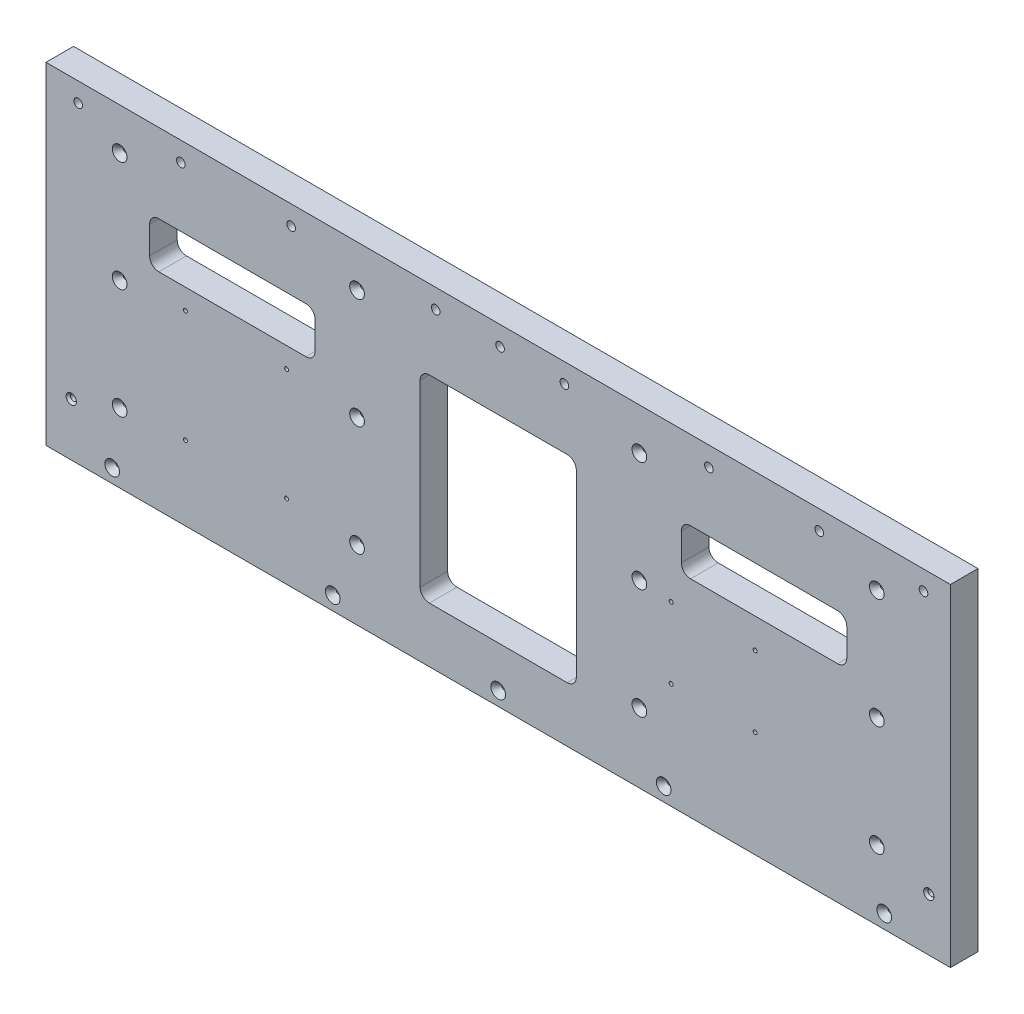
from build123d import *

# Parameters (mm, degrees)
SKETCH1_W                                         = 624.84
SKETCH1_H                                         = 229.235
BOSS_EXTRUDE1_DEPTH                               = 19.05
F_5_64_0_07813_DIAMETER_HOLE1_D                   = 3.175
F_5_64_0_07813_DIAMETER_HOLE1_DEPTH               = 38.1
F_5_64_0_07813_DIAMETER_HOLE1_CSINK_D             = 10.16
F_5_64_0_07813_DIAMETER_HOLE1_CSINK_ANGLE         = 82
F_5_64_0_07813_DIAMETER_HOLE1_TIP                 = 0.953866233
F_15_64_0_23438_DIAMETER_HOLE1_D                  = 5.953252
F_15_64_0_23438_DIAMETER_HOLE1_DEPTH              = 19.05
F_2_CLEARANCE_HOLE1_D                             = 2.7051
F_2_CLEARANCE_HOLE1_DEPTH                         = 19.05
F_2_CLEARANCE_HOLE2_D                             = 2.7051
F_2_CLEARANCE_HOLE2_DEPTH                         = 19.05
CSK_FOR_6_FLAT_HEAD_MACHINE_SCREW_100_D           = 4.3053
CSK_FOR_6_FLAT_HEAD_MACHINE_SCREW_100_DEPTH       = 19.05
CSK_FOR_6_FLAT_HEAD_MACHINE_SCREW_100_CSINK_D     = 7.0866
CSK_FOR_6_FLAT_HEAD_MACHINE_SCREW_100_CSINK_ANGLE = 82
CUT_EXTRUDE2_REACH                                = 21.05
SKETCH18_W                                        = 114.3
SKETCH18_H                                        = 31.75
SKETCH18_W_2                                      = 107.95
SKETCH18_H_2                                      = 136.525
FILLET2_R                                         = 6.35


with BuildPart() as part:
    # Sketch1 → Boss-Extrude1 (new body)
    with BuildSketch(Plane.XY):
        with Locations((-183.67375, -247.3325)):
            Rectangle(SKETCH1_W, SKETCH1_H)
    extrude(amount=BOSS_EXTRUDE1_DEPTH)

    # 5/64 (0.07813) Diameter Hole1
    with Locations(Plane(origin=(-182.40375, -6471.459863233, 19.05), x_dir=(1, 0, 0), z_dir=(0, 0, 1))):
        with Locations((-262.8265, 6157.452363233), (-98.7933, 6157.452363233), (-262.8265, 6233.652363233), (-98.7933, 6233.652363233), (-262.8265, 6309.852363233), (-98.7933, 6309.852363233), (-267.97, 6119.034863233), (-115.57, 6119.034863233), (-1.27, 6119.034863233), (113.03, 6119.034863233), (265.43, 6119.034863233), (96.2533, 6309.852363233), (260.2865, 6309.852363233), (96.2533, 6233.652363233), (260.2865, 6233.652363233), (96.2533, 6157.452363233), (260.2865, 6157.452363233)):
            CounterSinkHole(F_5_64_0_07813_DIAMETER_HOLE1_D / 2, F_5_64_0_07813_DIAMETER_HOLE1_CSINK_D / 2, depth=F_5_64_0_07813_DIAMETER_HOLE1_DEPTH, counter_sink_angle=F_5_64_0_07813_DIAMETER_HOLE1_CSINK_ANGLE)
            with Locations((0, 0, -(F_5_64_0_07813_DIAMETER_HOLE1_DEPTH + F_5_64_0_07813_DIAMETER_HOLE1_TIP / 2))):  # 118° drill point
                Cone(0, F_5_64_0_07813_DIAMETER_HOLE1_D / 2, F_5_64_0_07813_DIAMETER_HOLE1_TIP, mode=Mode.SUBTRACT)

    # 15/64 (0.23438) Diameter Hole1
    with Locations(Plane(origin=(0, 0, 0), x_dir=(-1, 0, 0), z_dir=(0, 0, -1))):
        with Locations((402.9075, -146.05), (326.7075, -146.05), (226.85375, -146.05), (182.40375, -146.05), (137.95375, -146.05), (38.1, -146.05), (-38.1, -146.05), (473.86875, -146.05), (-110.1471, -146.05)):
            Hole(F_15_64_0_23438_DIAMETER_HOLE1_D / 2, depth=F_15_64_0_23438_DIAMETER_HOLE1_DEPTH)

    # #2 Clearance Hole1
    with Locations(Plane.XY.offset(19.05)):
        with Locations((-6.23545, -239.6), (-64.23545, -239.6), (-64.23545, -288.6), (-6.23545, -288.6)):
            Hole(F_2_CLEARANCE_HOLE1_D / 2, depth=F_2_CLEARANCE_HOLE1_DEPTH)

    # #2 Clearance Hole2
    with Locations(Plane(origin=(0, 0, 0), x_dir=(-1, 0, 0), z_dir=(0, 0, -1))):
        with Locations((399.72615, -233.172), (329.87615, -233.172), (329.87615, -310.642), (399.72615, -310.642)):
            Hole(F_2_CLEARANCE_HOLE2_D / 2, depth=F_2_CLEARANCE_HOLE2_DEPTH)

    # CSK for #6 Flat Head Machine Screw (100)1
    with Locations(Plane.XY.offset(19.05)):
        with Locations((113.823564524, -325.434443918), (-478.63125, -325.4375)):
            CounterSinkHole(CSK_FOR_6_FLAT_HEAD_MACHINE_SCREW_100_D / 2, CSK_FOR_6_FLAT_HEAD_MACHINE_SCREW_100_CSINK_D / 2, depth=CSK_FOR_6_FLAT_HEAD_MACHINE_SCREW_100_DEPTH, counter_sink_angle=CSK_FOR_6_FLAT_HEAD_MACHINE_SCREW_100_CSINK_ANGLE)

    # Sketch18 → Cut-Extrude2 (cut, up to next)
    with BuildSketch(Plane(origin=(0, 0, 0), x_dir=(-1, 0, 0), z_dir=(0, 0, -1)), mode=Mode.PRIVATE) as cut_extrude2_sk1:
        with Locations((0.00635, -203.2)):
            Rectangle(SKETCH18_W, SKETCH18_H)
    cut_extrude2_tool1 = extrude(cut_extrude2_sk1.sketch, amount=-CUT_EXTRUDE2_REACH, mode=Mode.PRIVATE) & part.part
    add(cut_extrude2_tool1.solids().sort_by_distance((-0.00635, -203.2, 0))[0], mode=Mode.SUBTRACT)
    # Sketch18 → Cut-Extrude2 (cut, up to next)
    with BuildSketch(Plane(origin=(0, 0, 0), x_dir=(-1, 0, 0), z_dir=(0, 0, -1)), mode=Mode.PRIVATE) as cut_extrude2_sk2:
        with Locations((367.34115, -203.2)):
            Rectangle(SKETCH18_W, SKETCH18_H)
    cut_extrude2_tool2 = extrude(cut_extrude2_sk2.sketch, amount=-CUT_EXTRUDE2_REACH, mode=Mode.PRIVATE) & part.part
    add(cut_extrude2_tool2.solids().sort_by_distance((-367.34115, -203.2, 0))[0], mode=Mode.SUBTRACT)
    # Sketch18 → Cut-Extrude2 (cut, up to next)
    with BuildSketch(Plane(origin=(0, 0, 0), x_dir=(-1, 0, 0), z_dir=(0, 0, -1)), mode=Mode.PRIVATE) as cut_extrude2_sk3:
        with Locations((183.67375, -255.5875)):
            Rectangle(SKETCH18_W_2, SKETCH18_H_2)
    cut_extrude2_tool3 = extrude(cut_extrude2_sk3.sketch, amount=-CUT_EXTRUDE2_REACH, mode=Mode.PRIVATE) & part.part
    add(cut_extrude2_tool3.solids().sort_by_distance((-183.67375, -255.5875, 0))[0], mode=Mode.SUBTRACT)

    # Fillet2
    fillet2_edges = [part.edges().sort_by_distance(p)[0] for p in [
        (57.14365, -219.075, 9.525),
        (57.14365, -187.325, 9.525),
        (-57.15635, -187.325, 9.525),
        (-57.15635, -219.075, 9.525),
        (-310.19115, -187.325, 9.525),
        (-424.49115, -187.325, 9.525),
        (-424.49115, -219.075, 9.525),
        (-310.19115, -219.075, 9.525),
        (-129.69875, -323.85, 9.525),
        (-129.69875, -187.325, 9.525),
        (-237.64875, -187.325, 9.525),
        (-237.64875, -323.85, 9.525),
    ]]
    fillet(fillet2_edges, radius=FILLET2_R)


solid = part.part
